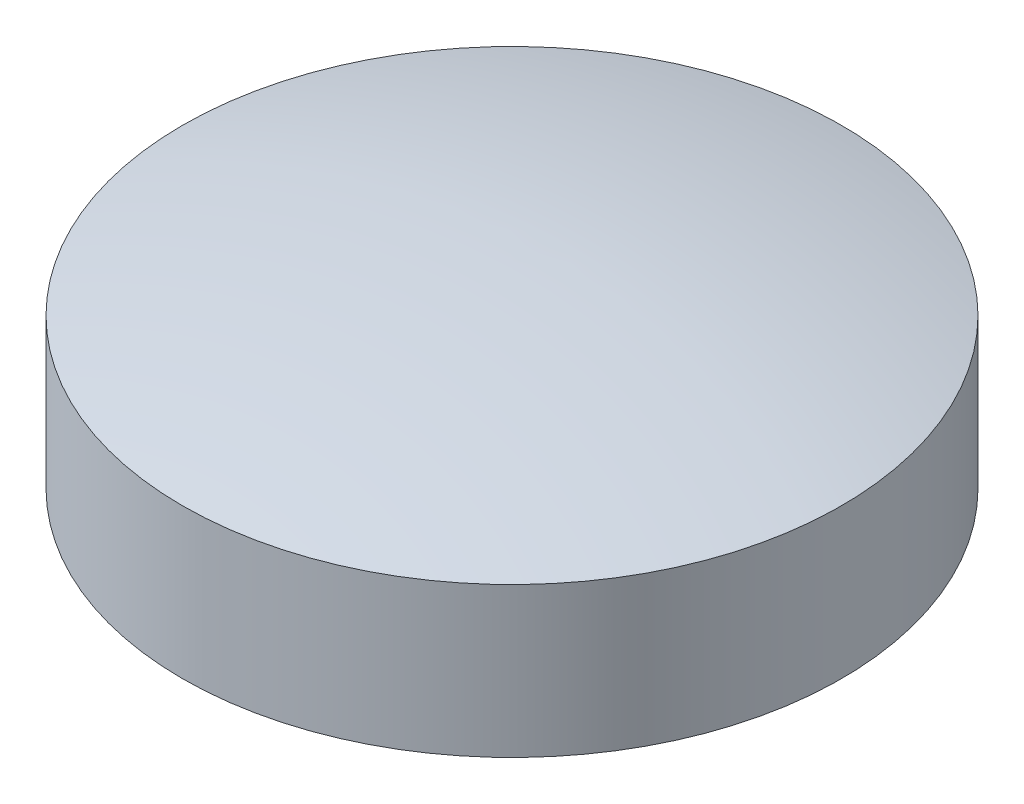
from build123d import *

# Parameters (mm, degrees)
SKETCH2_R          = 1.5
CUT_EXTRUDE1_DEPTH = 5


with BuildPart() as part:
    # Sketch1 → Revolve1 (revolve)
    with BuildSketch(Plane.XY, mode=Mode.PRIVATE) as revolve1_sk:
        with BuildLine():
            Line((0, 0), (-22, 0))
            Line((-22, 0), (-22, 10))
            ThreePointArc((-22, 10), (-11.101801656, 12.246545474), (0, 13))
            Line((0, 13), (0, 0))
        make_face()
    revolve(revolve1_sk.sketch.rotate(Axis((0, 30, 0), (0, -1, 0)), 270), axis=Axis((0, 30, 0), (0, -1, 0)))  # turned: the seam where the file's is

    # Sketch2 → Cut-Extrude1 (cut)
    with BuildSketch(Plane.XZ):
        with Locations((-22, 0)):
            Circle(SKETCH2_R)
    extrude(amount=-CUT_EXTRUDE1_DEPTH, mode=Mode.SUBTRACT)


solid = part.part
